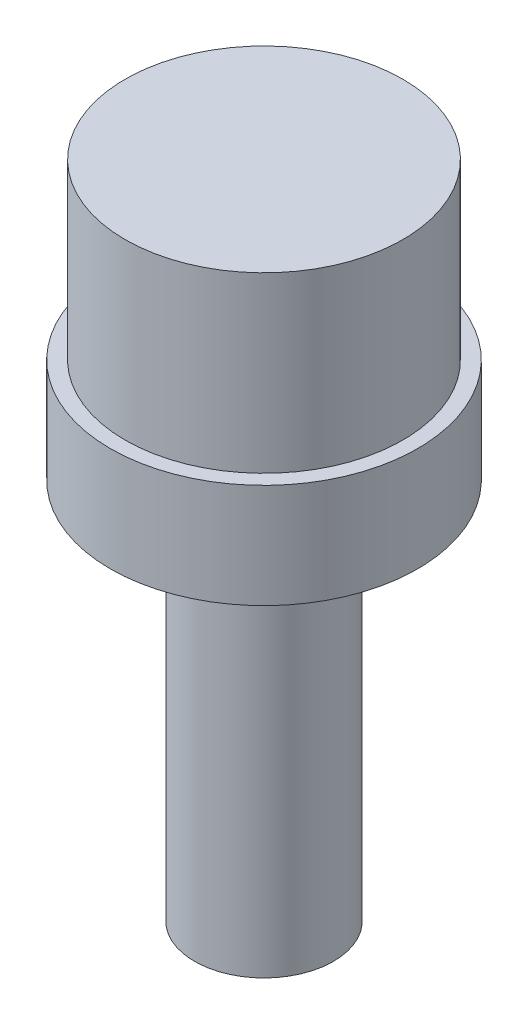
from build123d import *

# Parameters (mm, degrees)
SKETCH1_R           = 4.425
SKETCH1_R_2         = 2
SKETCH1_R_3         = 4
BOSS_EXTRUDE1_DEPTH = 3
SKETCH1_3_R         = 4
SKETCH1_3_R_2       = 2
BOSS_EXTRUDE2_DEPTH = 8
BOSS_EXTRUDE3_DEPTH = 11


with BuildPart() as part:
    # Sketch1 → Boss-Extrude1 (new body)
    with BuildSketch(Plane(origin=(0, 0, 0), x_dir=(1, 0, 0), z_dir=(0, 1, 0))):
        with BuildLine():
            ThreePointArc((1.322875656, 1.5), (0, 2), (-1.322875656, 1.5))
            Line((-1.322875656, 1.5), (1.322875656, 1.5))
        make_face()
        with BuildLine():
            Line((1.322875656, 1.5), (-1.322875656, 1.5))
            ThreePointArc((-1.322875656, 1.5), (-0.822875656, -1.822875656), (2, 0))
            ThreePointArc((2, 0), (1.822875656, 0.822875656), (1.322875656, 1.5))
        make_face()
        Circle(SKETCH1_R)
        Circle(SKETCH1_R_2, mode=Mode.SUBTRACT)
        Circle(SKETCH1_R)
        Circle(SKETCH1_R_3, mode=Mode.SUBTRACT)
    extrude(amount=BOSS_EXTRUDE1_DEPTH)

    # Sketch1_3 → Boss-Extrude2 (add)
    with BuildSketch(Plane(origin=(0, 0, 0), x_dir=(1, 0, 0), z_dir=(0, 1, 0))):
        Circle(SKETCH1_3_R)
        Circle(SKETCH1_3_R_2, mode=Mode.SUBTRACT)
        with BuildLine():
            ThreePointArc((1.322875656, 1.5), (0, 2), (-1.322875656, 1.5))
            Line((-1.322875656, 1.5), (1.322875656, 1.5))
        make_face()
        with BuildLine():
            Line((1.322875656, 1.5), (-1.322875656, 1.5))
            ThreePointArc((-1.322875656, 1.5), (-0.822875656, -1.822875656), (2, 0))
            ThreePointArc((2, 0), (1.822875656, 0.822875656), (1.322875656, 1.5))
        make_face()
    extrude(amount=BOSS_EXTRUDE2_DEPTH)

    # Sketch1_4 → Boss-Extrude3 (add)
    with BuildSketch(Plane(origin=(0, 0, 0), x_dir=(1, 0, 0), z_dir=(0, 1, 0))):
        with BuildLine():
            Line((1.322875656, 1.5), (-1.322875656, 1.5))
            ThreePointArc((-1.322875656, 1.5), (-0.822875656, -1.822875656), (2, 0))
            ThreePointArc((2, 0), (1.822875656, 0.822875656), (1.322875656, 1.5))
        make_face()
    extrude(amount=-BOSS_EXTRUDE3_DEPTH)


solid = part.part
